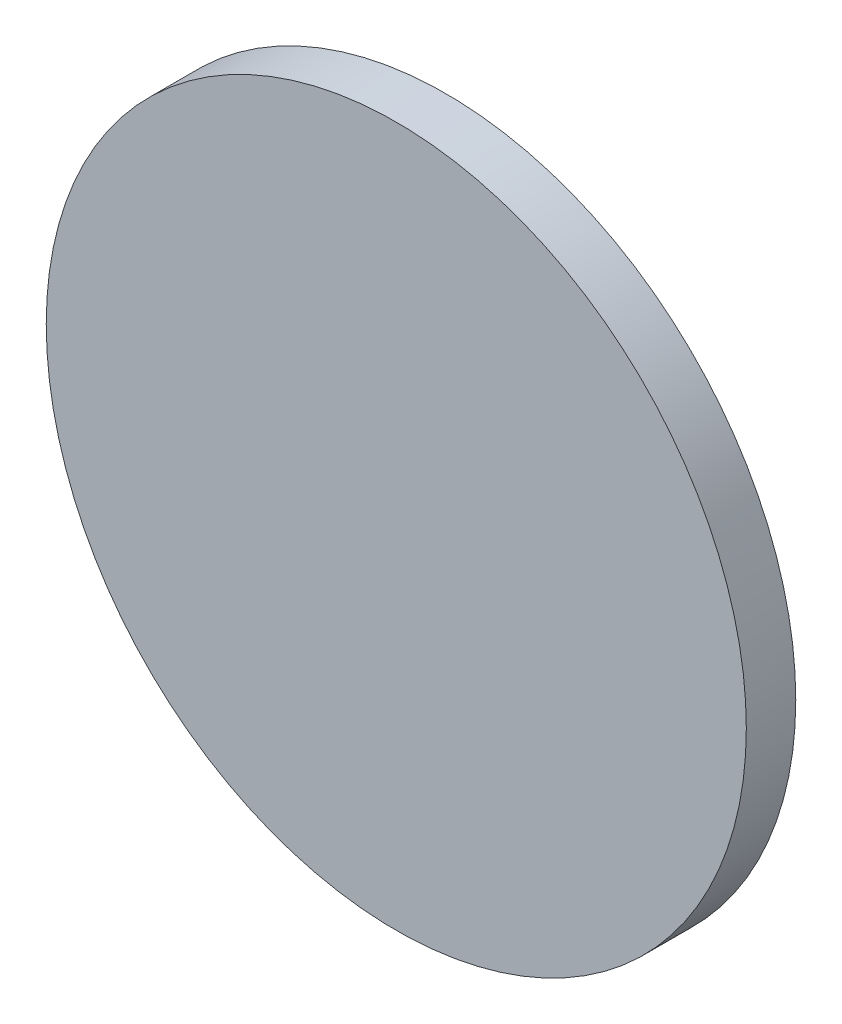
from build123d import *

# Parameters (mm, degrees)
SKETCH1_R           = 44.958
BOSS_EXTRUDE1_DEPTH = 6.35


with BuildPart() as part:
    # Sketch1 → Boss-Extrude1 (new body)
    with BuildSketch(Plane.XY):
        Circle(SKETCH1_R)
    extrude(amount=BOSS_EXTRUDE1_DEPTH)


solid = part.part
